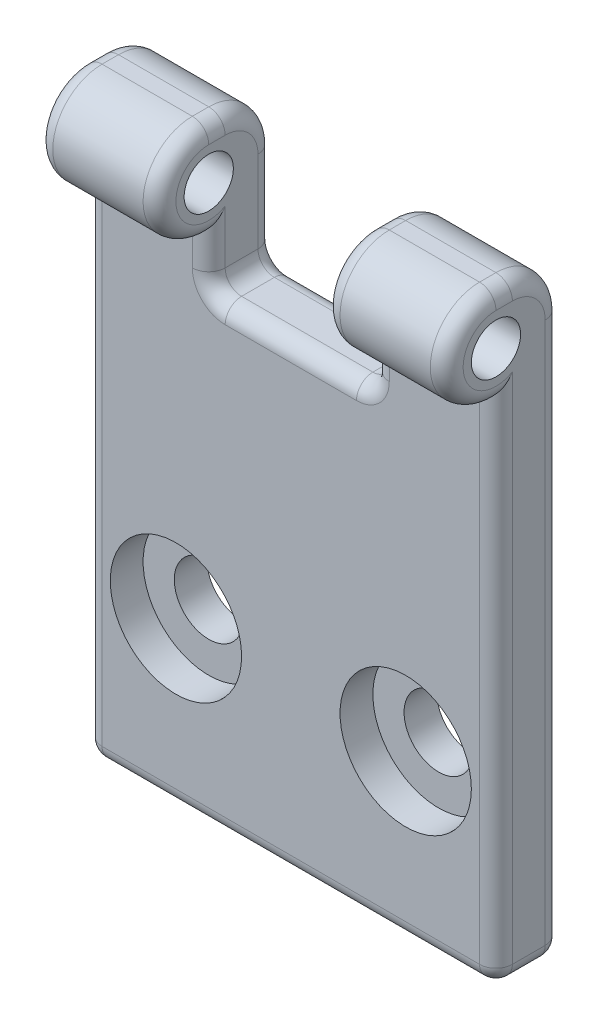
from build123d import *

# Parameters (mm, degrees)
ESQUISSE1_W                                       = 25
ESQUISSE1_H                                       = 37
BOSS_EXTRU_1_DEPTH                                = 4
ESQUISSE2_R                                       = 3
BOSS_EXTRU_2_DEPTH                                = 25
ESQUISSE3_R                                       = 1.5
ENL_V_MAT_EXTRU_1_DEPTH                           = 25
ENL_V_MAT_EXTRU_2_DEPTH                           = 25
ENL_V_MAT_EXTRU_2_DEPTH_BACK                      = 25
ESQUISSE4_W                                       = 10
ESQUISSE4_H                                       = 9
CHAMBRAGE_POUR_VIS_SIX_PANS_CREUX_M41_D           = 4.2
CHAMBRAGE_POUR_VIS_SIX_PANS_CREUX_M41_CBORE_D     = 8
CHAMBRAGE_POUR_VIS_SIX_PANS_CREUX_M41_CBORE_DEPTH = 2
CONG_1_R                                          = 1


with BuildPart() as part:
    # Esquisse1 → Boss.-Extru.1 (new body)
    with BuildSketch(Plane.XY):
        with Locations((12.5, 18.5)):
            Rectangle(ESQUISSE1_W, ESQUISSE1_H)
    extrude(amount=BOSS_EXTRU_1_DEPTH)

    # Esquisse2 → Boss.-Extru.2 (add)
    with BuildSketch(Plane(origin=(25, 0, 0), x_dir=(0, 0, -1), z_dir=(1, 0, 0))):
        with Locations((-4, 34)):
            Circle(ESQUISSE2_R)
    extrude(amount=-BOSS_EXTRU_2_DEPTH)

    # Esquisse3 → Enlèv. mat.-Extru.1 (cut)
    with BuildSketch(Plane(origin=(25, 0, 0), x_dir=(0, 0, -1), z_dir=(1, 0, 0))):
        with BuildLine():
            Line((0, 34), (0, 37))
            Line((0, 37), (-3, 37))
            ThreePointArc((-3, 37), (-0.878679656, 36.121320344), (0, 34))
        make_face()
        with Locations((-4, 34)):
            Circle(ESQUISSE3_R)
    extrude(amount=-ENL_V_MAT_EXTRU_1_DEPTH, mode=Mode.SUBTRACT)

    # Esquisse4 → Enlèv. mat.-Extru.2 (cut, two sides: drawn at the far end of the back side and taken through both)
    with BuildSketch(Plane.XY.offset(4).offset(-ENL_V_MAT_EXTRU_2_DEPTH_BACK)):
        with Locations((12.5, 32.5)):
            Rectangle(ESQUISSE4_W, ESQUISSE4_H)
    extrude(amount=ENL_V_MAT_EXTRU_2_DEPTH + ENL_V_MAT_EXTRU_2_DEPTH_BACK, mode=Mode.SUBTRACT)

    # Chambrage pour vis à six pans creux M41 (through all)
    with Locations(Plane(origin=(5.5, 10, 4), x_dir=(1, 0, 0), z_dir=(0, 0, 1))):
        with Locations((0, 0), (14, 0)):
            CounterBoreHole(CHAMBRAGE_POUR_VIS_SIX_PANS_CREUX_M41_D / 2, CHAMBRAGE_POUR_VIS_SIX_PANS_CREUX_M41_CBORE_D / 2, CHAMBRAGE_POUR_VIS_SIX_PANS_CREUX_M41_CBORE_DEPTH)

    # Congé1
    cong_1_edges = [part.edges().sort_by_distance(p)[0] for p in [
        (7.5, 34, 7),
        (17.5, 34, 7),
        (7.5, 37, 3.5),
        (17.5, 37, 3.5),
        (7.5, 36.121320344, 0.878679656),
        (17.5, 36.121320344, 0.878679656),
        (7.5, 29.5, 4),
        (7.5, 31, 0),
        (17.5, 29.5, 4),
        (17.5, 31, 0),
        (25, 34, 7),
        (25, 37, 3.5),
        (25, 36.121320344, 0.878679656),
        (0, 34, 7),
        (0, 37, 3.5),
        (0, 36.121320344, 0.878679656),
        (0, 0, 2),
        (12.5, 0, 4),
        (25, 0, 2),
        (12.5, 0, 0),
        (7.5, 28, 2),
        (17.5, 28, 2),
        (12.5, 28, 0),
        (12.5, 28, 4),
        (25, 15.5, 4),
        (25, 17, 0),
        (0, 15.5, 4),
        (0, 17, 0),
    ]]
    fillet(cong_1_edges, radius=CONG_1_R)


solid = part.part
